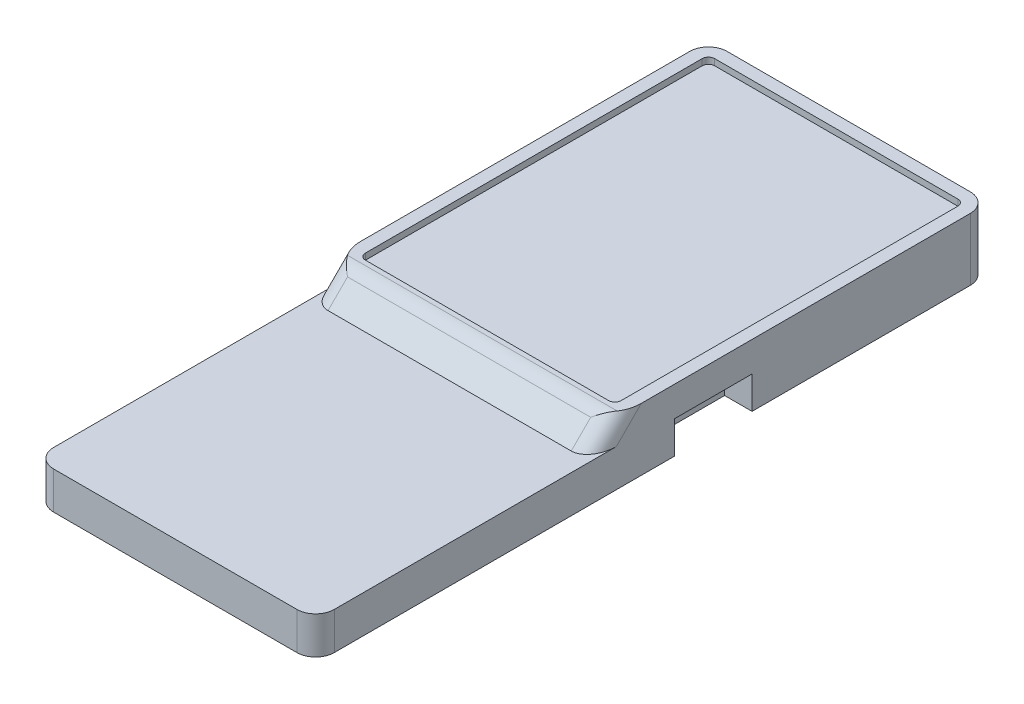
from build123d import *

# Parameters (mm, degrees)
SURFACE_SKETCH_W       = 22.5
SURFACE_SKETCH_H       = 30
BODY_DEPTH             = 4.5
SKETCH_19_W            = 22.5
SKETCH_19_H            = 24
EXTRUDE_4_DEPTH        = 3
FILLET_6_R             = 1.5
MAGNET_CUTOUT_SKETCH_W = 2.2
MAGNET_CUTOUT_SKETCH_H = 6.2
MAGNET_CUTOUT_DEPTH    = 2.6
BORDER_DEPTH           = 0.5
CHAMPFER_DEPTH         = 22.5
FILLET_7_R             = 1.5
FILLET_8_R             = 0.5
CUT_EXTRUDE_1_DEPTH    = 23.5


with BuildPart() as part:
    # surface_sketch → body (new body)
    with BuildSketch(Plane(origin=(0, 0, 0), x_dir=(1, 0, 0), z_dir=(0, 1, 0))):
        with Locations((-1.15, 0)):
            Rectangle(SURFACE_SKETCH_W, SURFACE_SKETCH_H)
    extrude(amount=-BODY_DEPTH)

    # Эскиз19 → Бобышка-Вытянуть4 (add)
    with BuildSketch(Plane(origin=(0, -4.5, 0), x_dir=(1, 0, 0), z_dir=(0, 1, 0))):
        with Locations((-1.15, -27)):
            Rectangle(SKETCH_19_W, SKETCH_19_H)
    extrude(amount=EXTRUDE_4_DEPTH)

    # Скругление6
    fillet_6_edges = [part.edges().sort_by_distance(p)[0] for p in [
        (-12.4, -3, 39),
        (10.1, -3, 39),
        (10.1, -2.25, -15),
        (-12.4, -2.25, -15),
    ]]
    fillet(fillet_6_edges, radius=FILLET_6_R)

    # magnet_cutout_sketch → magnet_cutout (cut)
    with BuildSketch(Plane.XZ.offset(4.5)):
        with Locations((9, 7.1)):
            Rectangle(MAGNET_CUTOUT_SKETCH_W, MAGNET_CUTOUT_SKETCH_H)
    magnet_cutout = extrude(amount=-MAGNET_CUTOUT_DEPTH, mode=Mode.SUBTRACT)

    # magnet_cutout_mirror: magnet_cutout across plane
    add(magnet_cutout.mirror(Plane(origin=(-1.15, 0, 0), x_dir=(0, 0, 1), z_dir=(1, 0, 0))), mode=Mode.SUBTRACT)

    # border_sketch → border (add)
    with BuildSketch(Plane(origin=(0, 0, 0), x_dir=(1, 0, 0), z_dir=(0, 1, 0))):
        with BuildLine():
            Line((-12.4, -15), (-12.4, 13.5))
            ThreePointArc((-12.4, 13.5), (-11.960660172, 14.560660172), (-10.9, 15))
            Line((-10.9, 15), (8.6, 15))
            ThreePointArc((8.6, 15), (9.660660172, 14.560660172), (10.1, 13.5))
            Line((10.1, 13.5), (10.1, -15))
            Line((10.1, -15), (9.1, -15))
            Line((9.1, -15), (9.1, 13.5))
            ThreePointArc((9.1, 13.5), (8.953553391, 13.853553391), (8.6, 14))
            Line((8.6, 14), (-10.9, 14))
            ThreePointArc((-10.9, 14), (-11.253553391, 13.853553391), (-11.4, 13.5))
            Line((-11.4, 13.5), (-11.4, -15))
            Line((-11.4, -15), (-12.4, -15))
        make_face()
    extrude(amount=BORDER_DEPTH)

    # Эскиз21 → champfer (add)
    with BuildSketch(Plane.ZY.offset(12.4)):
        Polygon((15, 0.5), (17, -1.5), (15, -1.5), (14, -1.5), (14, 0.5), align=None)
    extrude(amount=-CHAMPFER_DEPTH)

    # Скругление7
    fillet_7_edges = [part.edges().sort_by_distance(p)[0] for p in [
        (-12.4, -0.5, 16),
        (10.1, -0.5, 16),
    ]]
    fillet(fillet_7_edges, radius=FILLET_7_R)

    # Скругление8
    fillet_8_edges = [part.edges().sort_by_distance(p)[0] for p in [
        (9.1, 0.25, 14),
        (-11.4, 0.25, 14),
    ]]
    fillet(fillet_8_edges, radius=FILLET_8_R)

    # Эскиз22 → Вырез-Вытянуть1 (cut, through all)
    with BuildSketch(Plane.ZY.offset(12.4)):
        with BuildLine():
            Line((12.878679656, 0.5), (14.378679656, 0.5))
            ThreePointArc((14.378679656, 0.5), (14.952704805, 0.385819299), (15.439339828, 0.060660172))
            Line((15.439339828, 0.060660172), (17, -1.5))
            Line((17, -1.5), (17.923275361, -1.5))
            Line((17.923275361, -1.5), (15.181180077, 1.242095285))
            Line((15.181180077, 1.242095285), (12.878679656, 1.122407091))
            Line((12.878679656, 1.122407091), (12.878679656, 0.5))
        make_face()
    extrude(amount=-CUT_EXTRUDE_1_DEPTH, mode=Mode.SUBTRACT)


solid = part.part
